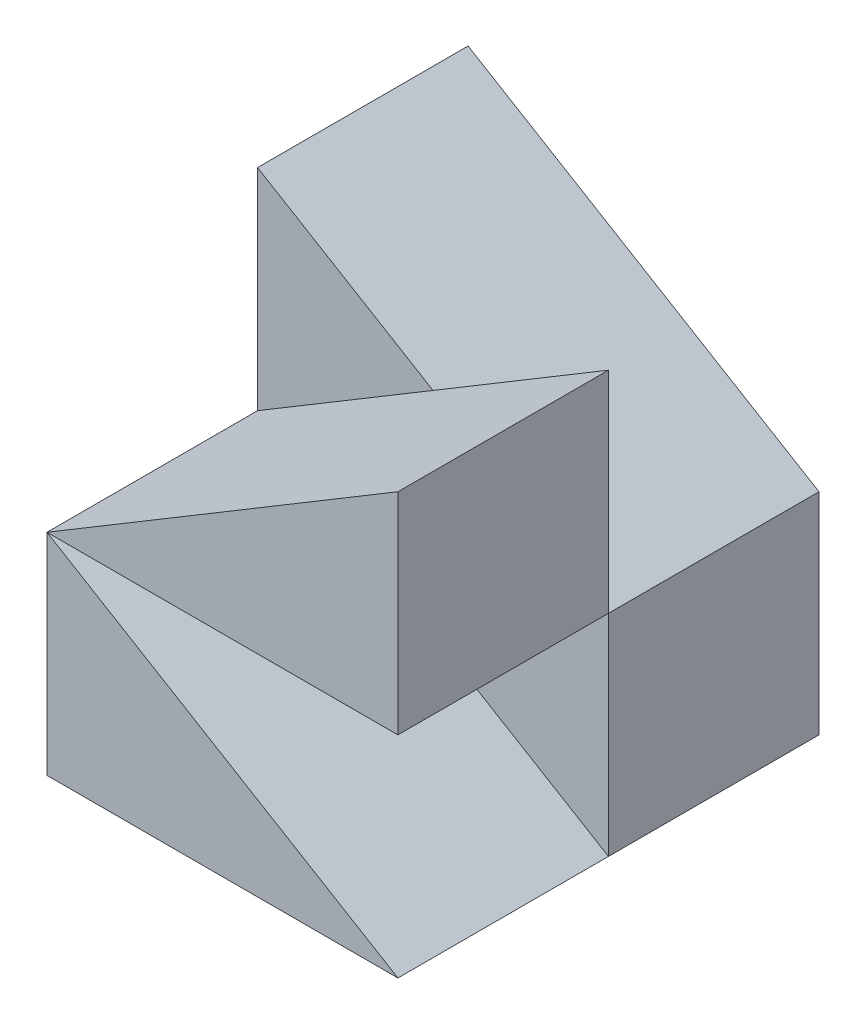
from build123d import *

# Parameters (mm, degrees)
BOSS_EXTRUDE1_DEPTH = 15
BOSS_EXTRUDE2_DEPTH = 15
BOSS_EXTRUDE3_DEPTH = 15
BOSS_EXTRUDE4_DEPTH = 15


with BuildPart() as part:
    # Sketch1 → Boss-Extrude1 (new body)
    with BuildSketch(Plane.XY):
        Polygon((-25, 0), (0, 15), (0, 0), align=None)
    extrude(amount=BOSS_EXTRUDE1_DEPTH)

    # Sketch3 → Boss-Extrude3 (add)
    with BuildSketch(Plane.XY.offset(15)):
        Polygon((0, 0), (-25, 0), (-25, 15), align=None)
    extrude(amount=BOSS_EXTRUDE3_DEPTH)


with BuildPart() as body_2:
    # Sketch2 → Boss-Extrude2 (new body)
    with BuildSketch(Plane(origin=(0, 0, 0), x_dir=(-1, 0, 0), z_dir=(0, 0, -1))):
        Polygon((0, 15), (25.000468659, 15), (25.000468659, 30), align=None)
    extrude(amount=-BOSS_EXTRUDE2_DEPTH)

    # Sketch4 → Boss-Extrude4 (add)
    with BuildSketch(Plane.XY.offset(15)):
        Polygon((-25.000468659, 15), (0, 15), (0, 30), align=None)
    extrude(amount=BOSS_EXTRUDE4_DEPTH)


solid = Compound([part.part, body_2.part])
